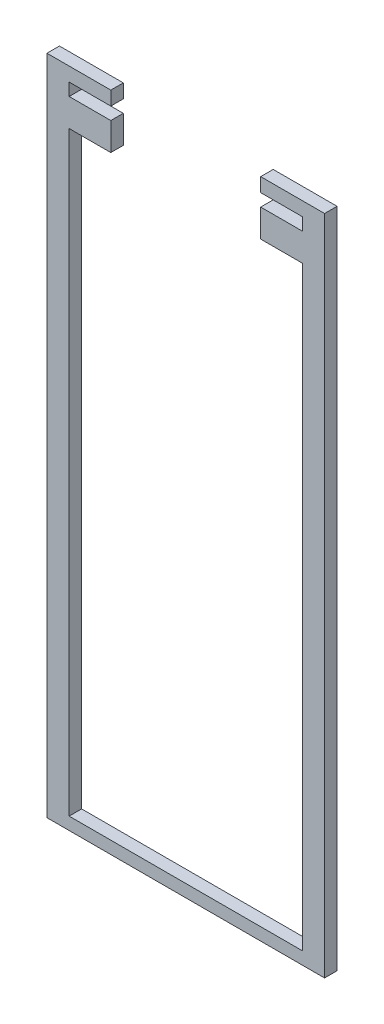
from build123d import *

# Parameters (mm, degrees)
BOSS_EXTRUDE1_DEPTH = 4.5


with BuildPart() as part:
    # Sketch2 → Boss-Extrude1 (new body)
    with BuildSketch(Plane.XY):
        Polygon((40.120933275, 117.892622477), (40.120933275, 122.392622477), (25.120933275, 122.392622477), (25.120933275, 127.392622477), (48.120933275, 127.392622477), (48.120933275, -111.107377523), (-51.879066725, -111.107377523), (-51.879066725, 127.392622477), (-28.879066725, 127.392622477), (-28.879066725, 122.392622477), (-43.879066725, 122.392622477), (-43.879066725, 117.892622477), (-28.879066725, 117.892622477), (-28.879066725, 107.892622477), (-43.879066725, 107.892622477), (-43.879066725, -106.607377523), (40.120933275, -106.607377523), (40.120933275, 107.892622477), (25.120933275, 107.892622477), (25.120933275, 117.892622477), align=None)
    extrude(amount=BOSS_EXTRUDE1_DEPTH)


solid = part.part
